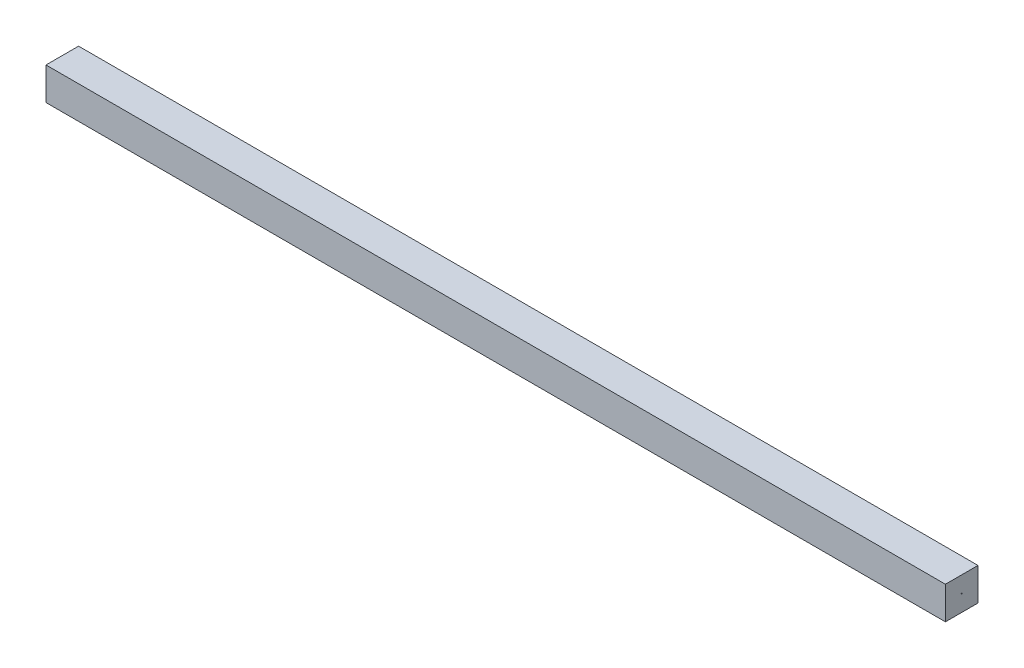
from build123d import *

# Parameters (mm, degrees)
SKETCH1_W           = 30
SKETCH1_H           = 30
BOSS_EXTRUDE2_DEPTH = 414
SKETCH3_R           = 0.5
BOSS_EXTRUDE3_DEPTH = 0.25
SKETCH4_R           = 0.5
BOSS_EXTRUDE4_DEPTH = 0.25


with BuildPart() as part:
    # Sketch1 → Boss-Extrude2 (new body, symmetric)
    with BuildSketch(Plane(origin=(0, 0, 0), x_dir=(0, 0, -1), z_dir=(1, 0, 0))):
        with Locations((15, 15)):
            Rectangle(SKETCH1_W, SKETCH1_H)
    extrude(amount=BOSS_EXTRUDE2_DEPTH, both=True)

    # Sketch3 → Boss-Extrude3 (add, symmetric)
    with BuildSketch(Plane.ZY.offset(414)):
        with Locations((-15, 15)):
            Circle(SKETCH3_R)
    extrude(amount=BOSS_EXTRUDE3_DEPTH, both=True)

    # Sketch4 → Boss-Extrude4 (add, symmetric)
    with BuildSketch(Plane(origin=(414, 0, 0), x_dir=(0, 0, -1), z_dir=(1, 0, 0))):
        with Locations((15, 15)):
            Circle(SKETCH4_R)
    extrude(amount=BOSS_EXTRUDE4_DEPTH, both=True)


solid = part.part
